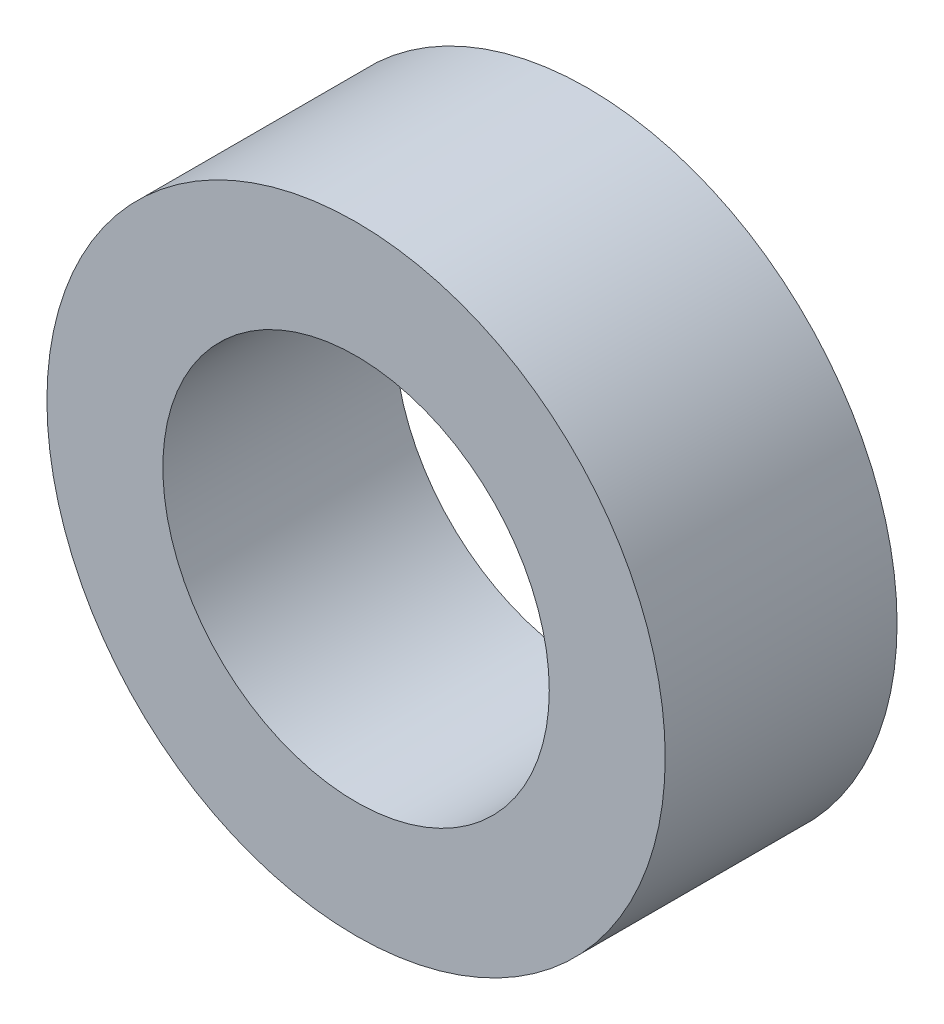
from build123d import *

# Parameters (mm, degrees)
SKETCH_1_R      = 4
SKETCH_1_R_2    = 2.5
EXTRUDE_1_DEPTH = 3


with BuildPart() as part:
    # 草图1 → 凸台-拉伸1 (new body)
    with BuildSketch(Plane.XY):
        Circle(SKETCH_1_R)
        Circle(SKETCH_1_R_2, mode=Mode.SUBTRACT)
    extrude(amount=EXTRUDE_1_DEPTH)


solid = part.part
